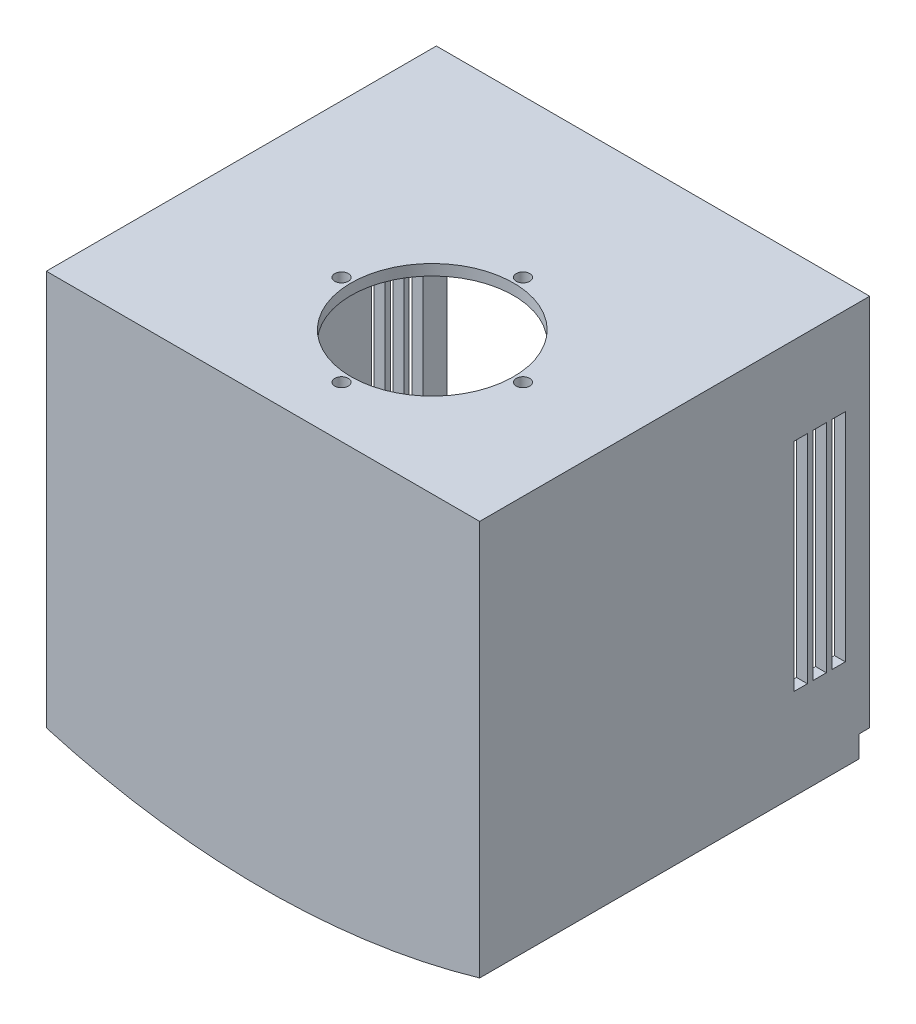
from build123d import *

# Parameters (mm, degrees)
BOSS_EXTRUDE1_DEPTH     = 35
SHELL1_T                = -2
SKETCH3_R               = 15
SKETCH3_R_2             = 1.25
CUT_EXTRUDE2_DEPTH      = 2
SKETCH4_W               = 2.5
SKETCH4_H               = 40
CUT_EXTRUDE3_DEPTH      = 1
CUT_EXTRUDE3_DEPTH_BACK = 81
BOSS_EXTRUDE2_DEPTH     = 2


with BuildPart() as part:
    # Sketch1 → Boss-Extrude1 (new body, symmetric)
    with BuildSketch(Plane.XY):
        with BuildLine():
            Line((-40, -137.291660344), (-40, -64.291660344))
            Line((-40, -64.291660344), (40, -64.291660344))
            Line((40, -64.291660344), (40, -137.291660344))
            ThreePointArc((40, -137.291660344), (0, -143), (-40, -137.291660344))
        make_face()
    extrude(amount=BOSS_EXTRUDE1_DEPTH, both=True)

    # Shell1
    shell1_openings = [part.faces().sort_by_distance(p)[0] for p in [
        (0, -102.218745258, -35),
    ]]
    offset(amount=SHELL1_T, openings=shell1_openings, kind=Kind.INTERSECTION)

    # Sketch3 → Cut-Extrude2 (cut)
    with BuildSketch(Plane(origin=(0, -64.291660344, 0), x_dir=(1, 0, 0), z_dir=(0, 1, 0))):
        with Locations((5, -8.75)):
            Circle(SKETCH3_R)
        with Locations((5, 8)):
            Circle(SKETCH3_R_2)
        with Locations((21.75, -8.75)):
            Circle(SKETCH3_R_2)
        with Locations((-11.75, -8.75)):
            Circle(SKETCH3_R_2)
        with Locations((5, -25.5)):
            Circle(SKETCH3_R_2)
    extrude(amount=-CUT_EXTRUDE2_DEPTH, mode=Mode.SUBTRACT)

    # Sketch4 → Cut-Extrude3 (cut, two sides)
    with BuildSketch(Plane(origin=(40, 0, 0), x_dir=(0, 0, -1), z_dir=(1, 0, 0))) as cut_extrude3_sk:
        with Locations((24.25, -100.496660344)):
            Rectangle(SKETCH4_W, SKETCH4_H)
        with Locations((27.75, -100.496660344)):
            Rectangle(SKETCH4_W, SKETCH4_H)
        with Locations((31.25, -100.496660344)):
            Rectangle(SKETCH4_W, SKETCH4_H)
    extrude(amount=CUT_EXTRUDE3_DEPTH, mode=Mode.SUBTRACT)
    extrude(cut_extrude3_sk.sketch, amount=-CUT_EXTRUDE3_DEPTH_BACK, mode=Mode.SUBTRACT)

    # Sketch6 → Boss-Extrude2 (add)
    with BuildSketch(Plane(origin=(0, 0, -35), x_dir=(-1, 0, 0), z_dir=(0, 0, -1))):
        Polygon((-40, -64.291660344), (-40, -133.291660344), (-38, -133.291660344), (-38, -66.291660344), (38, -66.291660344), (38, -133.291660344), (40, -133.291660344), (40, -64.291660344), align=None)
    extrude(amount=BOSS_EXTRUDE2_DEPTH)


solid = part.part
